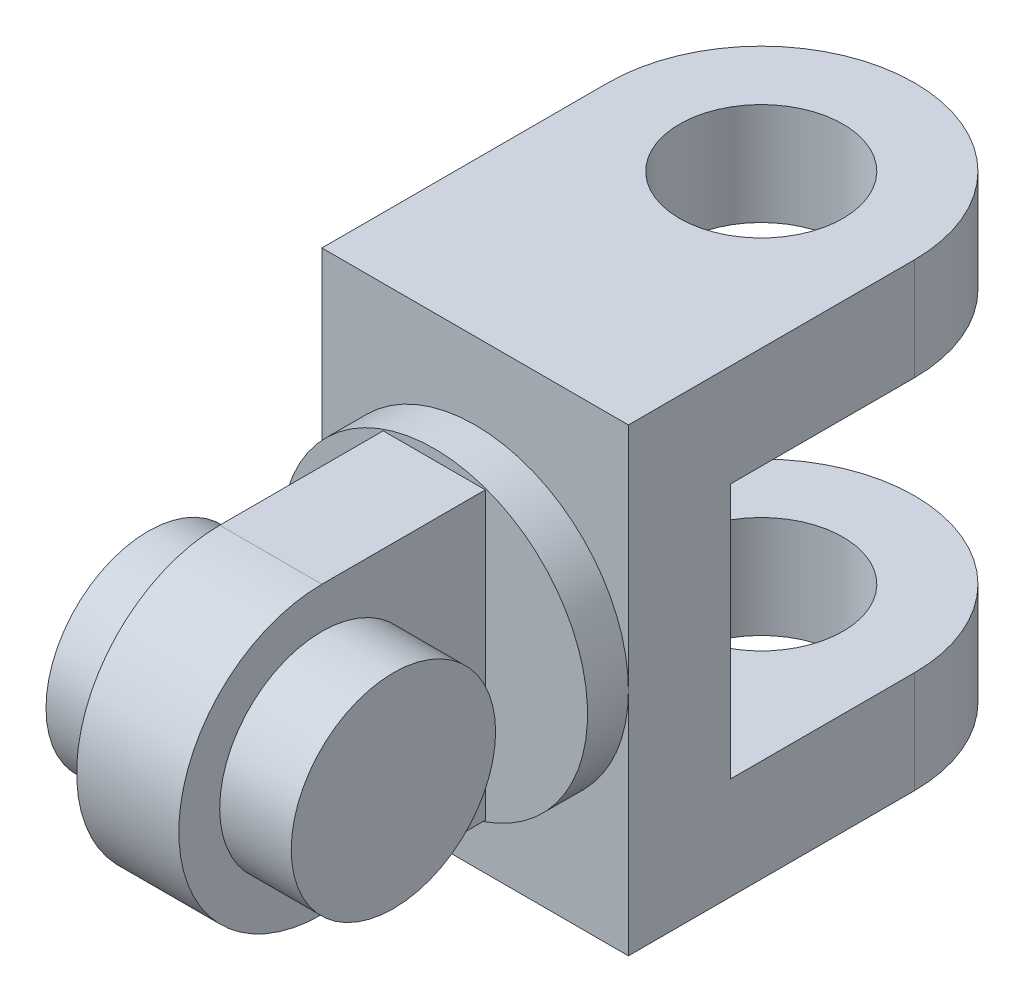
from build123d import *

# Parameters (mm, degrees)
SKETCH1_R           = 10
BOSS_EXTRUDE1_DEPTH = 12
BOSS_EXTRUDE2_DEPTH = 5
SKETCH3_R           = 15
BOSS_EXTRUDE3_DEPTH = 4
SKETCH5_W           = 30
SKETCH5_H           = 45
BOSS_EXTRUDE4_DEPTH = 10
BOSS_EXTRUDE5_START = 12.5
SKETCH7_R           = 8
BOSS_EXTRUDE5_DEPTH = 10
BOSS_EXTRUDE6_START = -12.5
SKETCH7_2_R         = 8
BOSS_EXTRUDE6_DEPTH = 10


with BuildPart() as part:
    # Sketch1 → Boss-Extrude1 (new body, symmetric)
    with BuildSketch(Plane(origin=(0, 0, 0), x_dir=(0, 0, -1), z_dir=(1, 0, 0))):
        Circle(SKETCH1_R)
    extrude(amount=BOSS_EXTRUDE1_DEPTH, both=True)

    # Sketch2 → Boss-Extrude2 (add, symmetric)
    with BuildSketch(Plane(origin=(0, 0, 0), x_dir=(0, 0, -1), z_dir=(1, 0, 0))):
        with BuildLine():
            Line((0, 14), (16, 14))
            Line((16, 14), (16, -14))
            Line((16, -14), (0, -14))
            ThreePointArc((0, -14), (-14, 0), (0, 14))
        make_face()
    extrude(amount=BOSS_EXTRUDE2_DEPTH, both=True)

    # Sketch3 → Boss-Extrude3 (add)
    with BuildSketch(Plane(origin=(0, 0, -16), x_dir=(-1, 0, 0), z_dir=(0, 0, -1))):
        Circle(SKETCH3_R)
    extrude(amount=BOSS_EXTRUDE3_DEPTH)

    # Sketch5 → Boss-Extrude4 (add)
    with BuildSketch(Plane(origin=(0, 0, -20), x_dir=(-1, 0, 0), z_dir=(0, 0, -1))):
        Rectangle(SKETCH5_W, SKETCH5_H)
    extrude(amount=BOSS_EXTRUDE4_DEPTH)

    # Sketch7 → Boss-Extrude5 (add)
    with BuildSketch(Plane(origin=(0, 0, 0), x_dir=(1, 0, 0), z_dir=(0, 1, 0)).offset(BOSS_EXTRUDE5_START)):
        with BuildLine():
            Line((-15, 30), (-15, 48))
            ThreePointArc((-15, 48), (0, 63), (15, 48))
            Line((15, 48), (15, 30))
            Line((15, 30), (-15, 30))
        make_face()
        with Locations((0, 48)):
            Circle(SKETCH7_R, mode=Mode.SUBTRACT)
    extrude(amount=BOSS_EXTRUDE5_DEPTH)

    # Sketch7_2 → Boss-Extrude6 (add)
    with BuildSketch(Plane(origin=(0, 0, 0), x_dir=(1, 0, 0), z_dir=(0, 1, 0)).offset(BOSS_EXTRUDE6_START)):
        with BuildLine():
            Line((-15, 30), (-15, 48))
            ThreePointArc((-15, 48), (0, 63), (15, 48))
            Line((15, 48), (15, 30))
            Line((15, 30), (-15, 30))
        make_face()
        with Locations((0, 48)):
            Circle(SKETCH7_2_R, mode=Mode.SUBTRACT)
    extrude(amount=-BOSS_EXTRUDE6_DEPTH)


solid = part.part
